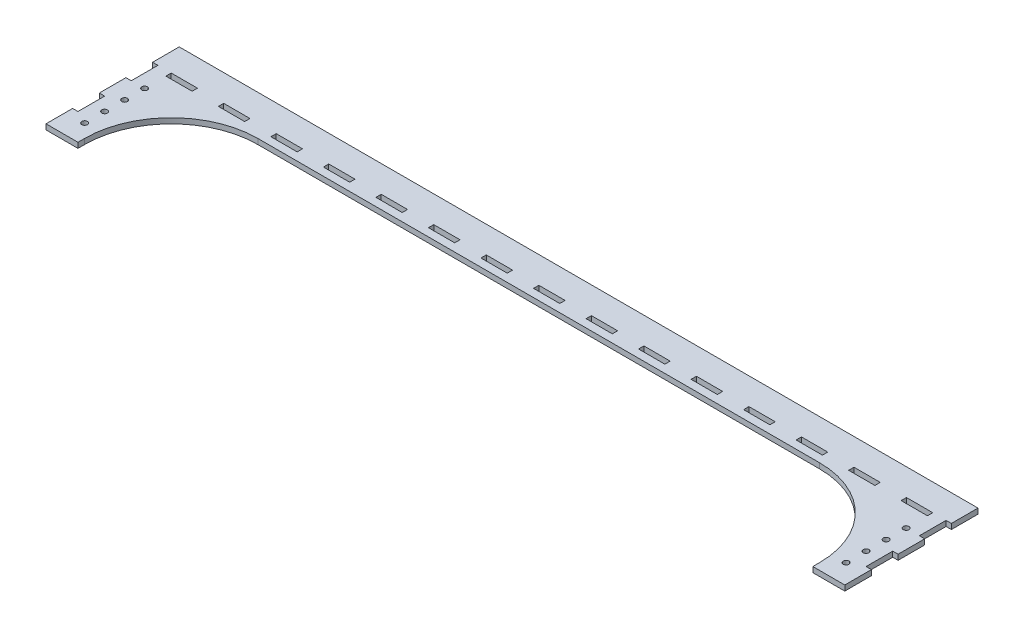
from build123d import *

# Parameters (mm, degrees)
SKETCH1_R           = 2.125
SKETCH1_W           = 19.725
SKETCH1_H           = 4
BOSS_EXTRUDE1_DEPTH = 4


with BuildPart() as part:
    # Sketch1 → Boss-Extrude1 (new body)
    with BuildSketch(Plane(origin=(0, 0, 0), x_dir=(1, 0, 0), z_dir=(0, 1, 0))):
        with BuildLine():
            Line((299.8, 24), (299.8, 4))
            Line((299.8, 4), (295.8, 4))
            Line((295.8, 4), (295.8, -16))
            Line((295.8, -16), (299.8, -16))
            Line((299.8, -16), (299.8, -36))
            Line((299.8, -36), (295.8, -36))
            Line((295.8, -36), (295.8, -56))
            Line((295.8, -56), (299.8, -56))
            Line((299.8, -56), (299.8, -76))
            Line((299.8, -76), (275.8, -76))
            Line((275.8, -76), (275.8, -71))
            ThreePointArc((275.8, -71), (256.761940777, -25.038059223), (210.8, -6))
            Line((210.8, -6), (-210.8, -6))
            ThreePointArc((-210.8, -6), (-256.761940777, -25.038059223), (-275.8, -71))
            Line((-275.8, -71), (-275.8, -76))
            Line((-275.8, -76), (-299.8, -76))
            Line((-299.8, -76), (-299.8, -56))
            Line((-299.8, -56), (-295.8, -56))
            Line((-295.8, -56), (-295.8, -36))
            Line((-295.8, -36), (-299.8, -36))
            Line((-299.8, -36), (-299.8, -16))
            Line((-299.8, -16), (-295.8, -16))
            Line((-295.8, -16), (-295.8, 4))
            Line((-295.8, 4), (-299.8, 4))
            Line((-299.8, 4), (-299.8, 24))
            Line((-299.8, 24), (299.8, 24))
        make_face()
        with Locations((285.8, -61)):
            Circle(SKETCH1_R, mode=Mode.SUBTRACT)
        with Locations((285.8, -46)):
            Circle(SKETCH1_R, mode=Mode.SUBTRACT)
        with Locations((-285.8, -46)):
            Circle(SKETCH1_R, mode=Mode.SUBTRACT)
        with Locations((-285.8, -61)):
            Circle(SKETCH1_R, mode=Mode.SUBTRACT)
        with Locations((285.8, -16)):
            Circle(SKETCH1_R, mode=Mode.SUBTRACT)
        with Locations((285.8, -31)):
            Circle(SKETCH1_R, mode=Mode.SUBTRACT)
        with Locations((-285.8, -31)):
            Circle(SKETCH1_R, mode=Mode.SUBTRACT)
        with Locations((-285.8, -16)):
            Circle(SKETCH1_R, mode=Mode.SUBTRACT)
        with Locations((0, 2)):
            Rectangle(SKETCH1_W, SKETCH1_H, mode=Mode.SUBTRACT)
        with Locations((39.45, 2)):
            Rectangle(SKETCH1_W, SKETCH1_H, mode=Mode.SUBTRACT)
        with Locations((78.87, 2)):
            Rectangle(SKETCH1_W, SKETCH1_H, mode=Mode.SUBTRACT)
        with Locations((118.29, 2)):
            Rectangle(SKETCH1_W, SKETCH1_H, mode=Mode.SUBTRACT)
        with Locations((157.71, 2)):
            Rectangle(SKETCH1_W, SKETCH1_H, mode=Mode.SUBTRACT)
        with Locations((197.13, 2)):
            Rectangle(SKETCH1_W, SKETCH1_H, mode=Mode.SUBTRACT)
        with Locations((236.55, 2)):
            Rectangle(SKETCH1_W, SKETCH1_H, mode=Mode.SUBTRACT)
        with Locations((275.97, 2)):
            Rectangle(SKETCH1_W, SKETCH1_H, mode=Mode.SUBTRACT)
        with Locations((-275.97, 2)):
            Rectangle(SKETCH1_W, SKETCH1_H, mode=Mode.SUBTRACT)
        with Locations((-236.55, 2)):
            Rectangle(SKETCH1_W, SKETCH1_H, mode=Mode.SUBTRACT)
        with Locations((-197.13, 2)):
            Rectangle(SKETCH1_W, SKETCH1_H, mode=Mode.SUBTRACT)
        with Locations((-157.71, 2)):
            Rectangle(SKETCH1_W, SKETCH1_H, mode=Mode.SUBTRACT)
        with Locations((-118.29, 2)):
            Rectangle(SKETCH1_W, SKETCH1_H, mode=Mode.SUBTRACT)
        with Locations((-78.87, 2)):
            Rectangle(SKETCH1_W, SKETCH1_H, mode=Mode.SUBTRACT)
        with Locations((-39.45, 2)):
            Rectangle(SKETCH1_W, SKETCH1_H, mode=Mode.SUBTRACT)
    extrude(amount=BOSS_EXTRUDE1_DEPTH)


solid = part.part
